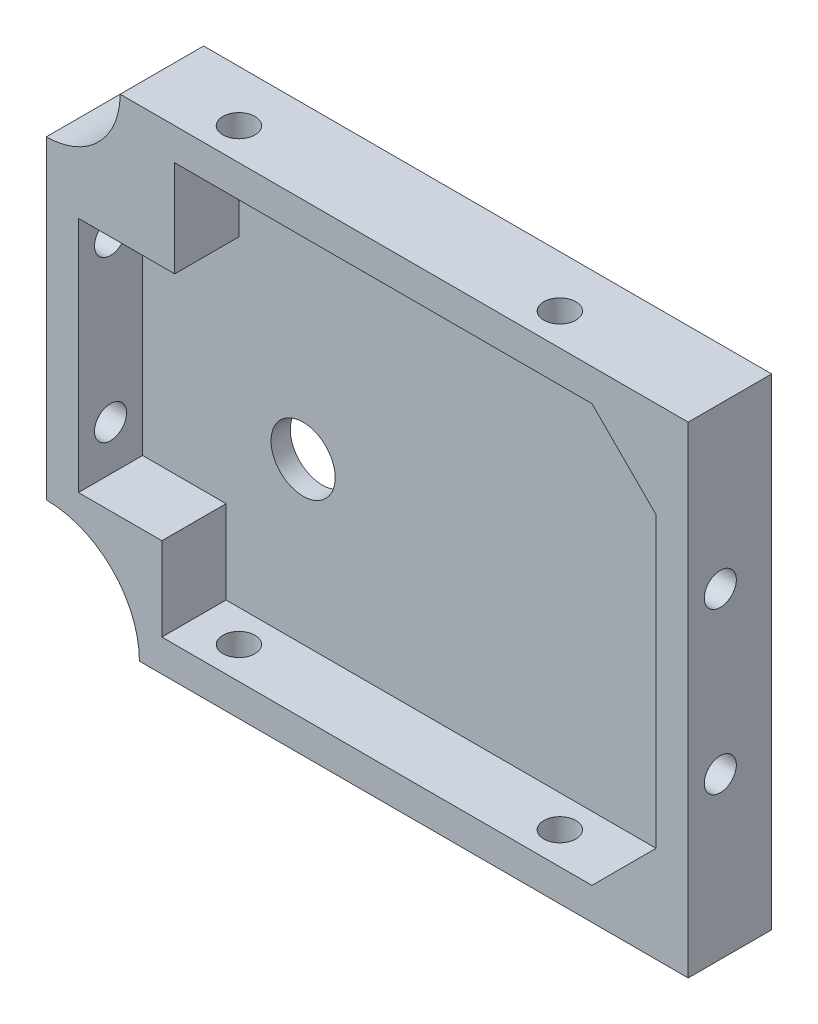
from build123d import *

# Parameters (mm, degrees)
BOSS_EXTRU_1_DEPTH        = 13
COQUE1_T                  = -5
COQUE1_THICKNESS_2_FACE_W = 90
COQUE1_THICKNESS_2_FACE_H = 65
COQUE1_THICKNESS_2_DEPTH  = 2
ENL_V_MAT_EXTRU_1_REACH   = 110.96
ESQUISSE2_R               = 2.5
ENL_V_MAT_EXTRU_2_REACH   = 95.396
ESQUISSE3_R               = 2.5
ESQUISSE4_W               = 18
ESQUISSE4_H               = 18
ESQUISSE4_W_2             = 15
ESQUISSE4_H_2             = 15
BOSS_EXTRU_2_DEPTH        = 10
ESQUISSE6_R               = 11.5
ESQUISSE6_R_2             = 14.5
ENL_V_MAT_EXTRU_4_DEPTH   = 13
ESQUISSE7_R               = 5
ENL_V_MAT_EXTRU_5_DEPTH   = 3


with BuildPart() as part:
    # Esquisse1 → Boss.-Extru.1 (new body)
    with BuildSketch(Plane.XY):
        Polygon((44.118436308, 33.728448276), (54.118436308, 33.728448276), (54.118436308, 23.728448276), (54.118436308, -41.271551724), (-45.881563692, -41.271551724), (-45.881563692, 33.728448276), align=None)
    extrude(amount=BOSS_EXTRU_1_DEPTH)

    # Coque1
    coque1_openings = [part.faces().sort_by_distance(p)[0] for p in [
        (4.118436308, -3.771551724, 13),
    ]]
    offset(amount=COQUE1_T, openings=coque1_openings, kind=Kind.INTERSECTION)

    # Coque1 thickness 2 face (on inner face of the shell) → Coque1 thickness 2 (cut)
    with BuildSketch(Plane(origin=(4.118436308, -3.771551724, 5), x_dir=(-1, 0, 0), z_dir=(0, 0, -1))):
        Rectangle(COQUE1_THICKNESS_2_FACE_W, COQUE1_THICKNESS_2_FACE_H)
    extrude(amount=COQUE1_THICKNESS_2_DEPTH, mode=Mode.SUBTRACT)

    # Enlèv. mat.-Extru.1: up to this face of the body (flat: up to its plane)
    enl_v_mat_extru_1_end = Plane(part.part.faces().sort_by_distance((54.118436308, -3.771551724, 6.5))[0])
    # Esquisse2 → Enlèv. mat.-Extru.1 (cut, up to the picked face)
    with BuildSketch(Plane.ZY.offset(45.881563692), mode=Mode.PRIVATE) as enl_v_mat_extru_1_sk1:
        with Locations(Location((8, -16.271551724, 0), (0, 0, 270))):
            Circle(ESQUISSE2_R)
    enl_v_mat_extru_1_tool1 = split(extrude(enl_v_mat_extru_1_sk1.sketch, amount=-ENL_V_MAT_EXTRU_1_REACH, mode=Mode.PRIVATE), bisect_by=enl_v_mat_extru_1_end, keep=Keep.BOTH, mode=Mode.PRIVATE)
    # Esquisse2 → Enlèv. mat.-Extru.1 (cut, up to the picked face)
    with BuildSketch(Plane.ZY.offset(45.881563692), mode=Mode.PRIVATE) as enl_v_mat_extru_1_sk2:
        with Locations(Location((8, 8.728448276, 0), (0, 0, 270))):
            Circle(ESQUISSE2_R)
    enl_v_mat_extru_1_tool2 = split(extrude(enl_v_mat_extru_1_sk2.sketch, amount=-ENL_V_MAT_EXTRU_1_REACH, mode=Mode.PRIVATE), bisect_by=enl_v_mat_extru_1_end, keep=Keep.BOTH, mode=Mode.PRIVATE)
    add(enl_v_mat_extru_1_tool1.solids().sort_by(Axis((-45.881564, -16.271552, 8), (1, 0, 0)))[0], mode=Mode.SUBTRACT)
    add(enl_v_mat_extru_1_tool2.solids().sort_by(Axis((-45.881564, 8.728448, 8), (1, 0, 0)))[0], mode=Mode.SUBTRACT)

    # Enlèv. mat.-Extru.2: up to this face of the body (flat: up to its plane)
    enl_v_mat_extru_2_end = Plane(part.part.faces().sort_by_distance((4.118436308, 33.728448276, 6.5))[0])
    # Esquisse3 → Enlèv. mat.-Extru.2 (cut, up to the picked face)
    with BuildSketch(Plane.XZ.offset(41.271551724), mode=Mode.PRIVATE) as enl_v_mat_extru_2_sk1:
        with Locations(Location((-20.881563692, 8, 0), (0, 0, 270))):
            Circle(ESQUISSE3_R)
    enl_v_mat_extru_2_tool1 = split(extrude(enl_v_mat_extru_2_sk1.sketch, amount=-ENL_V_MAT_EXTRU_2_REACH, mode=Mode.PRIVATE), bisect_by=enl_v_mat_extru_2_end, keep=Keep.BOTH, mode=Mode.PRIVATE)
    # Esquisse3 → Enlèv. mat.-Extru.2 (cut, up to the picked face)
    with BuildSketch(Plane.XZ.offset(41.271551724), mode=Mode.PRIVATE) as enl_v_mat_extru_2_sk2:
        with Locations(Location((29.118436308, 8, 0), (0, 0, 270))):
            Circle(ESQUISSE3_R)
    enl_v_mat_extru_2_tool2 = split(extrude(enl_v_mat_extru_2_sk2.sketch, amount=-ENL_V_MAT_EXTRU_2_REACH, mode=Mode.PRIVATE), bisect_by=enl_v_mat_extru_2_end, keep=Keep.BOTH, mode=Mode.PRIVATE)
    add(enl_v_mat_extru_2_tool1.solids().sort_by(Axis((-20.881564, -41.271552, 8), (0, 1, 0)))[0], mode=Mode.SUBTRACT)
    add(enl_v_mat_extru_2_tool2.solids().sort_by(Axis((29.118436, -41.271552, 8), (0, 1, 0)))[0], mode=Mode.SUBTRACT)

    # Esquisse4 → Boss.-Extru.2 (add)
    with BuildSketch(Plane.XY.offset(3)):
        with Locations((-36.881563692, -32.271551724)):
            Rectangle(ESQUISSE4_W, ESQUISSE4_H)
        Polygon((49.118436308, 28.728448276), (49.118436308, 18.728448276), (39.118436308, 28.728448276), align=None)
        Polygon((49.118436308, -36.271551724), (49.118436308, -26.271551724), (39.118436308, -36.271551724), align=None)
        with Locations((-33.381563692, 21.228448276)):
            Rectangle(ESQUISSE4_W_2, ESQUISSE4_H_2)
    extrude(amount=BOSS_EXTRU_2_DEPTH)

    # Esquisse6 → Enlèv. mat.-Extru.4 (cut)
    with BuildSketch(Plane.XY.offset(13)):
        with Locations((-45.881563692, 33.728448276)):
            Circle(ESQUISSE6_R)
        with Locations((-45.881563692, -41.271551724)):
            Circle(ESQUISSE6_R_2)
    extrude(amount=-ENL_V_MAT_EXTRU_4_DEPTH, mode=Mode.SUBTRACT)

    # Esquisse7 → Enlèv. mat.-Extru.5 (cut)
    with BuildSketch(Plane.XY.offset(3)):
        with Locations((-15.881563692, -11.271551724)):
            Circle(ESQUISSE7_R)
    extrude(amount=-ENL_V_MAT_EXTRU_5_DEPTH, mode=Mode.SUBTRACT)


solid = part.part
